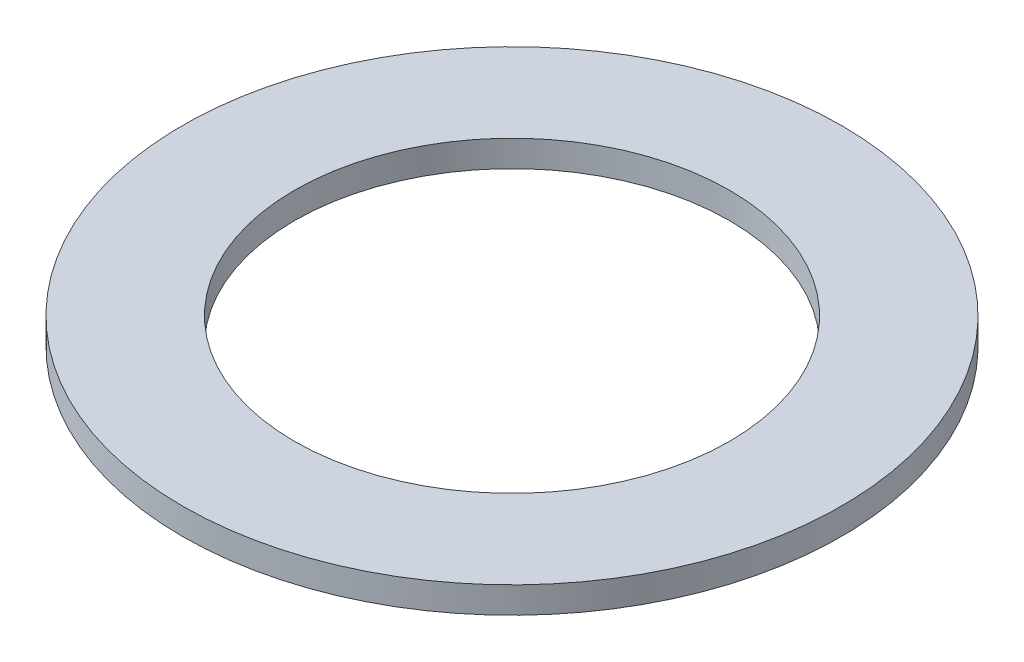
from build123d import *

# Parameters (mm, degrees)
SKETCH1_R           = 5
SKETCH1_R_2         = 3.3
BOSS_EXTRUDE1_DEPTH = 0.4


with BuildPart() as part:
    # Sketch1 → Boss-Extrude1 (new body)
    with BuildSketch(Plane(origin=(0, 0, 0), x_dir=(1, 0, 0), z_dir=(0, 1, 0))):
        with Locations((-6.317920845, 15.114095374)):
            Circle(SKETCH1_R)
        with Locations((-6.317920845, 15.114095374)):
            Circle(SKETCH1_R_2, mode=Mode.SUBTRACT)
    extrude(amount=BOSS_EXTRUDE1_DEPTH)


solid = part.part
